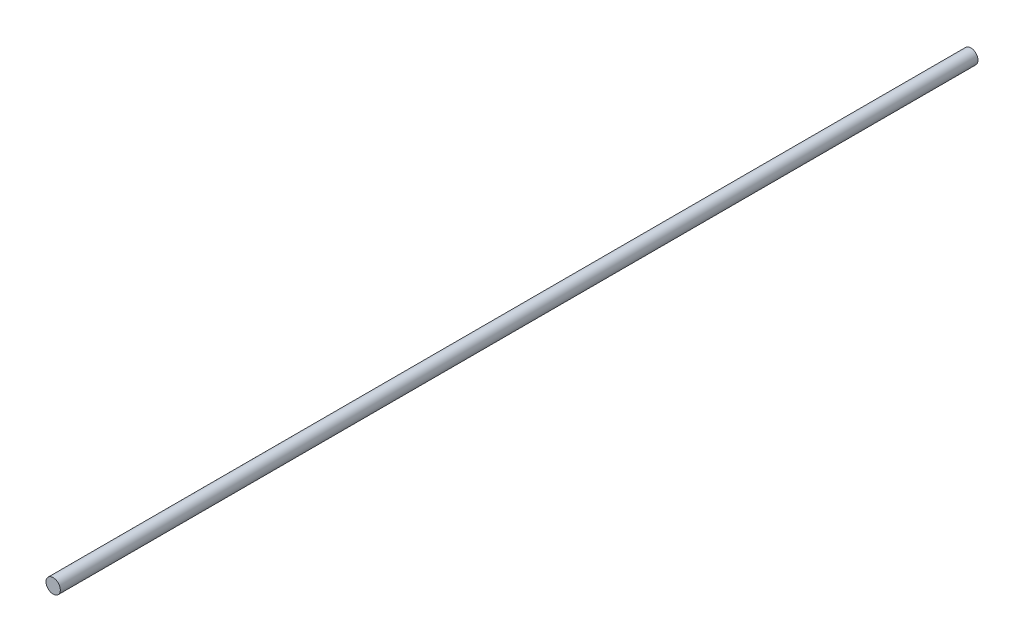
from build123d import *

# Parameters (mm, degrees)
SKETCH1_R           = 3.175
BOSS_EXTRUDE1_DEPTH = 406.4


with BuildPart() as part:
    # Sketch1 → Boss-Extrude1 (new body)
    with BuildSketch(Plane.XY):
        Circle(SKETCH1_R)
    extrude(amount=BOSS_EXTRUDE1_DEPTH)


solid = part.part
